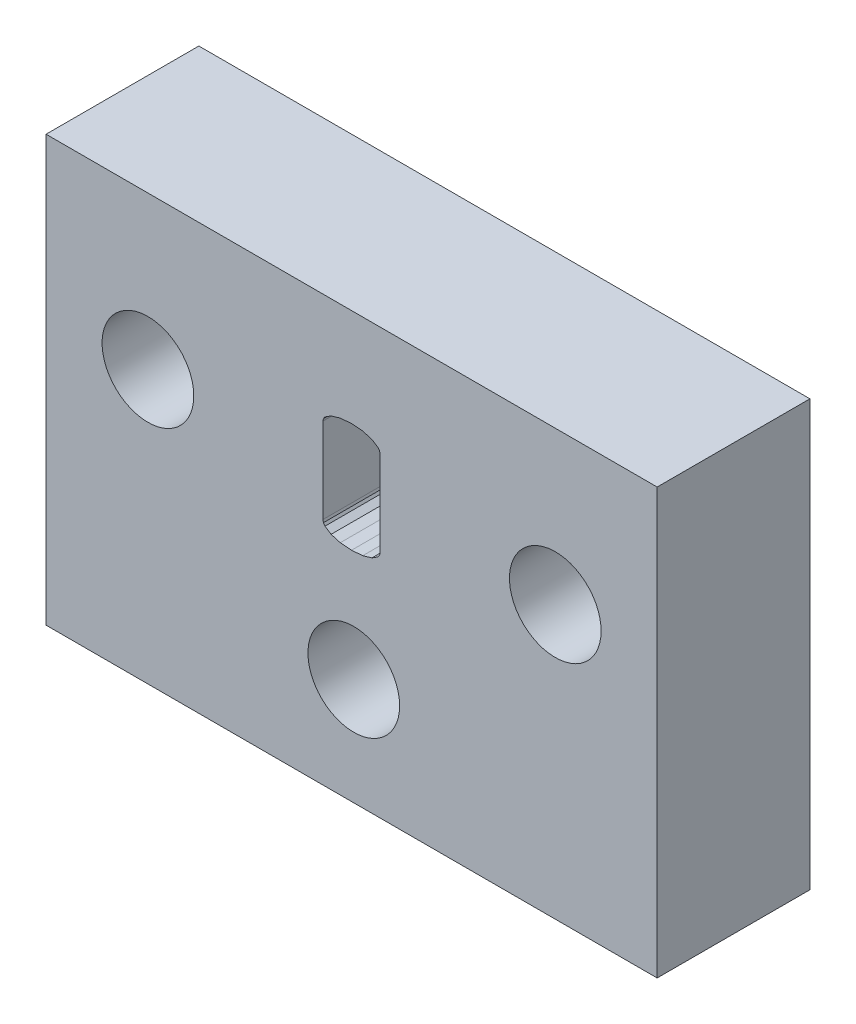
from build123d import *

# Parameters (mm, degrees)
MODEL_W                  = 23.99999232
MODEL_H                  = 16.699994656
MODEL_R                  = 1.8
RESSALTO_EXTRUS_O1_DEPTH = 6


with BuildPart() as part:
    # Model → Ressalto-extrusão1 (new body)
    with BuildSketch(Plane.XY):
        with Locations((43.7766695, 15.703554206)):
            Rectangle(MODEL_W, MODEL_H)
        with Locations((35.77667206, 18.053553454)):
            Circle(MODEL_R, mode=Mode.SUBTRACT)
        with Locations((43.861433665, 11.553555534)):
            Circle(MODEL_R, mode=Mode.SUBTRACT)
        with Locations((51.77555053, 18.053553454)):
            Circle(MODEL_R, mode=Mode.SUBTRACT)
        Polygon((42.649145536, 19.728924359), (42.649145536, 16.382506676), (42.669242478, 16.286318247), (42.729533303, 16.197543356), (42.970696603, 16.042234191), (43.332060456, 15.936872625), (43.77304988, 15.901752102), (44.214039305, 15.936872625), (44.575403158, 16.042234191), (44.816566458, 16.197543356), (44.876857283, 16.286318247), (44.896954225, 16.382506676), (44.896954225, 19.728924359), (44.876857283, 19.825112787), (44.816566458, 19.913887678), (44.575403158, 20.069196843), (44.214039305, 20.17455841), (43.77304988, 20.209678932), (43.332060456, 20.17455841), (42.970696603, 20.069196843), (42.729533303, 19.913887678), (42.669242478, 19.825112787), align=None, mode=Mode.SUBTRACT)
    extrude(amount=RESSALTO_EXTRUS_O1_DEPTH)


solid = part.part
